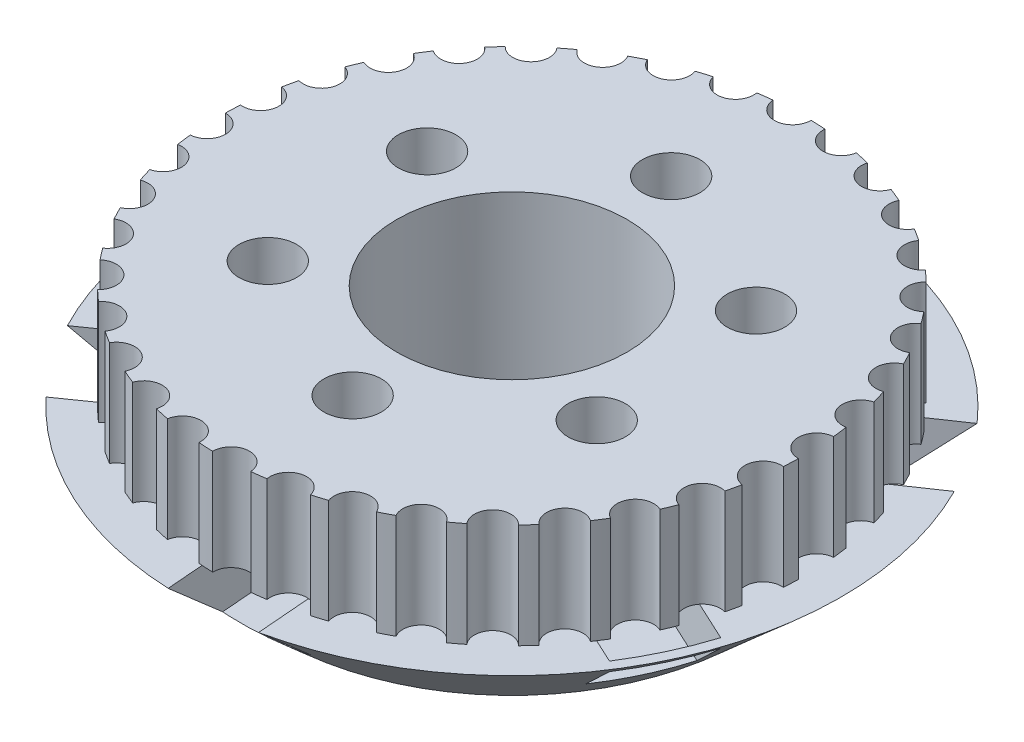
from build123d import *
from build123d.topology import SkipClean

# Parameters (mm, degrees)
SKETCH1_R               = 2.75
SKETCH1_R_2             = 11
BOSS_EXTRUDE1_DEPTH     = 10
SKETCH2_R               = 31.5
SKETCH3_R               = 22.5
CUT_EXTRUDE1_DEPTH      = 49.046852265
CUT_EXTRUDE1_DEPTH_BACK = 49.046852265
SKETCH3_4_R             = 11
CUT_EXTRUDE2_DEPTH      = 46.656325001
CUT_EXTRUDE2_DEPTH_BACK = 46.656325001
SKETCH1_4_R             = 2.75
CUT_EXTRUDE5_DEPTH      = 5


with BuildPart() as part:
    # Sketch1 → Boss-Extrude1 (new body)
    with BuildSketch(Plane(origin=(0, 0, 0), x_dir=(1, 0, 0), z_dir=(0, 1, 0))):
        with BuildLine():
            ThreePointArc((27.993478679, -0.604277614), (26.22801827, 1.074037998), (27.850343554, 2.891083518))
            ThreePointArc((27.850343554, 2.891083518), (27.77024444, 3.579598264), (27.673126544, 4.26591928))
            ThreePointArc((27.673126544, 4.26591928), (25.643050997, 5.612168524), (26.925202872, 7.683322869))
            ThreePointArc((26.925202872, 7.683322869), (26.726761313, 8.347468463), (26.511940461, 9.006498375))
            ThreePointArc((26.511940461, 9.006498375), (24.278932596, 9.979776149), (25.181953525, 12.242108342))
            ThreePointArc((25.181953525, 12.242108342), (24.871199067, 12.861705057), (24.545202484, 13.473419575))
            ThreePointArc((24.545202484, 13.473419575), (22.177111114, 14.044153326), (22.673563263, 16.428923548))
            ThreePointArc((22.673563263, 16.428923548), (22.259938023, 16.985145252), (21.832670949, 17.530957739))
            ThreePointArc((21.832670949, 17.530957739), (19.401449332, 17.681806011), (19.476248255, 20.116554226))
            ThreePointArc((19.476248255, 20.116554226), (18.972320026, 20.592500403), (18.456764755, 21.055826623))
            ThreePointArc((18.456764755, 21.055826623), (16.036284331, 20.782205967), (15.687157298, 23.192953583))
            ThreePointArc((15.687157298, 23.192953583), (15.108237686, 23.574162849), (14.520059104, 23.940924869))
            ThreePointArc((14.520059104, 23.940924869), (12.183864944, 23.251149112), (11.421420006, 25.564646781))
            ThreePointArc((11.421420006, 25.564646781), (10.785099188, 25.839536286), (10.142168805, 26.098590229))
            ThreePointArc((10.142168805, 26.098590229), (7.961244987, 25.013617856), (6.808648646, 27.159571124))
            ThreePointArc((6.808648646, 27.159571124), (6.13426091, 27.319788489), (5.456113839, 27.463263131))
            ThreePointArc((5.456113839, 27.463263131), (3.496726629, 26.01606048), (1.988999942, 27.929265641))
            ThreePointArc((1.988999942, 27.929265641), (1.297036218, 27.969942743), (0.604277614, 27.993478679))
            ThreePointArc((0.604277614, 27.993478679), (0.604339005, 27.985015849), (0.604359469, 27.976552821))
            ThreePointArc((0.604359469, 27.976552821), (-1.082494776, 26.227692446), (-2.891083518, 27.850343554))
            ThreePointArc((-2.891083518, 27.850343554), (-3.579598264, 27.77024444), (-4.26591928, 27.673126544))
            ThreePointArc((-4.26591928, 27.673126544), (-4.243730358, 27.51353932), (-4.236313092, 27.352587731))
            ThreePointArc((-4.236313092, 27.352587731), (-5.770984401, 25.615885812), (-7.683322869, 26.925202872))
            ThreePointArc((-7.683322869, 26.925202872), (-8.347468463, 26.726761313), (-9.006498375, 26.511940461))
            ThreePointArc((-9.006498375, 26.511940461), (-8.923170733, 26.209743316), (-8.895094559, 25.897528103))
            ThreePointArc((-8.895094559, 25.897528103), (-10.279221713, 24.186201991), (-12.242108342, 25.181953525))
            ThreePointArc((-12.242108342, 25.181953525), (-12.861705057, 24.871199067), (-13.473419575, 24.545202484))
            ThreePointArc((-13.473419575, 24.545202484), (-13.292270178, 24.116687878), (-13.230430214, 23.655585188))
            ThreePointArc((-13.230430214, 23.655585188), (-14.466797726, 21.982659109), (-16.428923548, 22.673563263))
            ThreePointArc((-16.428923548, 22.673563263), (-16.985145252, 22.259938023), (-17.530957739, 21.832670949))
            ThreePointArc((-17.530957739, 21.832670949), (-17.219044747, 21.301360185), (-17.110593078, 20.694879288))
            ThreePointArc((-17.110593078, 20.694879288), (-18.203110002, 19.073085218), (-20.116554226, 19.476248255))
            ThreePointArc((-20.116554226, 19.476248255), (-20.592500403, 18.972320026), (-21.055826623, 18.456764755))
            ThreePointArc((-21.055826623, 18.456764755), (-20.585242914, 17.85261337), (-20.417686365, 17.105369953))
            ThreePointArc((-20.417686365, 17.105369953), (-21.371356544, 15.547050725), (-23.192953583, 15.687157299))
            ThreePointArc((-23.192953583, 15.687157299), (-23.574162849, 15.108237686), (-23.940924869, 14.520059104))
            ThreePointArc((-23.940924869, 14.520059104), (-23.289930499, 13.878441572), (-23.051225719, 12.996122607))
            ThreePointArc((-23.051225719, 12.996122607), (-23.872109704, 11.513137972), (-25.564646781, 11.421420006))
            ThreePointArc((-25.564646781, 11.421420006), (-25.839536286, 10.785099188), (-26.098590229, 10.142168805))
            ThreePointArc((-26.098590229, 10.142168805), (-25.252547259, 9.502674185), (-24.93119238, 8.491994653))
            ThreePointArc((-24.93119238, 8.491994653), (-25.626361304, 7.095631018), (-27.159571124, 6.808648646))
            ThreePointArc((-27.159571124, 6.808648646), (-27.319788489, 6.13426091), (-27.463263131, 5.456113839))
            ThreePointArc((-27.463263131, 5.456113839), (-26.415342342, 4.861189956), (-26.000464512, 3.729841738))
            ThreePointArc((-26.000464512, 3.729841738), (-26.577946276, 2.430726274), (-27.929265641, 1.988999942))
            ThreePointArc((-27.929265641, 1.988999942), (-27.969942743, 1.297036218), (-27.993478679, 0.604277614))
            ThreePointArc((-27.993478679, 0.604277614), (-26.745114689, 0.09776613), (-26.226552821, -1.145640531))
            ThreePointArc((-26.226552821, -1.145640531), (-26.695270999, -2.337620771), (-27.850343554, -2.891083518))
            ThreePointArc((-27.850343554, -2.891083518), (-27.77024444, -3.579598264), (-27.673126544, -4.26591928))
            ThreePointArc((-27.673126544, -4.26591928), (-26.234205623, -4.640311063), (-25.602587731, -5.986313092))
            ThreePointArc((-25.602587731, -5.986313092), (-25.972293649, -7.062086418), (-26.925202872, -7.683322869))
            ThreePointArc((-26.925202872, -7.683322869), (-26.726761313, -8.347468463), (-26.511940461, -9.006498375))
            ThreePointArc((-26.511940461, -9.006498375), (-24.900713583, -9.206741051), (-24.147528103, -10.645094559))
            ThreePointArc((-24.147528103, -10.645094559), (-24.428726634, -11.596473687), (-25.181953525, -12.242108342))
            ThreePointArc((-25.181953525, -12.242108342), (-24.871199067, -12.861705057), (-24.545202484, -13.473419575))
            ThreePointArc((-24.545202484, -13.473419575), (-22.787924617, -13.460671966), (-21.905585188, -14.980430214))
            ThreePointArc((-21.905585188, -14.980430214), (-22.109454798, -15.800174574), (-22.673563263, -16.428923548))
            ThreePointArc((-22.673563263, -16.428923548), (-22.259938023, -16.985145252), (-21.832670949, -17.530957739))
            ThreePointArc((-21.832670949, -17.530957739), (-19.962976086, -17.270996367), (-18.944879288, -18.860593078))
            ThreePointArc((-18.944879288, -18.860593078), (-19.083186962, -19.542463921), (-19.476248255, -20.116554226))
            ThreePointArc((-19.476248255, -20.116554226), (-18.972320026, -20.592500403), (-18.456764755, -21.055826623))
            ThreePointArc((-18.456764755, -21.055826623), (-16.514794346, -20.520348982), (-15.355369953, -22.167686365))
            ThreePointArc((-15.355369953, -22.167686365), (-15.440381643, -22.706494241), (-15.687157298, -23.192953583))
            ThreePointArc((-15.687157298, -23.192953583), (-15.108237686, -23.574162849), (-14.520059104, -23.940924869))
            ThreePointArc((-14.520059104, -23.940924869), (-12.551369232, -23.108684897), (-11.246122607, -24.801225719))
            ThreePointArc((-11.246122607, -24.801225719), (-11.29050988, -25.192869976), (-11.421420006, -25.564646781))
            ThreePointArc((-11.421420006, -25.564646781), (-10.785099188, -25.839536286), (-10.142168805, -26.098590229))
            ThreePointArc((-10.142168805, -26.098590229), (-8.196448351, -24.956329376), (-6.741994653, -26.68119238))
            ThreePointArc((-6.741994653, -26.68119238), (-6.75873825, -26.922692368), (-6.808648646, -27.159571124))
            ThreePointArc((-6.808648646, -27.159571124), (-6.13426091, -27.319788489), (-5.456113839, -27.463263131))
            ThreePointArc((-5.456113839, -27.463263131), (-3.585751795, -26.006406574), (-1.979841738, -27.750464512))
            ThreePointArc((-1.979841738, -27.750464512), (-1.982132788, -27.83998227), (-1.988999942, -27.929265641))
            ThreePointArc((-1.988999942, -27.929265641), (-1.297036218, -27.969942743), (-0.604277614, -27.993478679))
            ThreePointArc((-0.604277614, -27.993478679), (1.074037998, -26.22801827), (2.891083518, -27.850343554))
            ThreePointArc((2.891083518, -27.850343554), (3.579598264, -27.77024444), (4.26591928, -27.673126544))
            ThreePointArc((4.26591928, -27.673126544), (5.612168524, -25.643050997), (7.683322869, -26.925202872))
            ThreePointArc((7.683322869, -26.925202872), (8.347468463, -26.726761312), (9.006498375, -26.511940461))
            ThreePointArc((9.006498375, -26.511940461), (9.979776149, -24.278932596), (12.242108342, -25.181953525))
            ThreePointArc((12.242108342, -25.181953525), (12.861705057, -24.871199067), (13.473419575, -24.545202484))
            ThreePointArc((13.473419575, -24.545202484), (14.044153326, -22.177111114), (16.428923548, -22.673563263))
            ThreePointArc((16.428923548, -22.673563263), (16.985145252, -22.259938023), (17.530957739, -21.832670949))
            ThreePointArc((17.530957739, -21.832670949), (17.681806011, -19.401449332), (20.116554226, -19.476248255))
            ThreePointArc((20.116554226, -19.476248255), (20.592500403, -18.972320026), (21.055826623, -18.456764755))
            ThreePointArc((21.055826623, -18.456764755), (20.782205967, -16.036284331), (23.192953583, -15.687157298))
            ThreePointArc((23.192953583, -15.687157298), (23.574162849, -15.108237686), (23.940924869, -14.520059104))
            ThreePointArc((23.940924869, -14.520059104), (23.251149112, -12.183864944), (25.564646781, -11.421420006))
            ThreePointArc((25.564646781, -11.421420006), (25.839536286, -10.785099188), (26.098590229, -10.142168805))
            ThreePointArc((26.098590229, -10.142168805), (25.013617856, -7.961244987), (27.159571124, -6.808648646))
            ThreePointArc((27.159571124, -6.808648646), (27.319788489, -6.13426091), (27.463263131, -5.456113839))
            ThreePointArc((27.463263131, -5.456113839), (26.01606048, -3.496726629), (27.929265641, -1.988999942))
            ThreePointArc((27.929265641, -1.988999942), (27.969942743, -1.297036218), (27.993478679, -0.604277614))
        make_face()
        with Locations((-13.718248072, -9.611044159)):
            Circle(SKETCH1_R, mode=Mode.SUBTRACT)
        Circle(SKETCH1_R_2, mode=Mode.SUBTRACT)
        with Locations((1.464284363, -16.685873406)):
            Circle(SKETCH1_R, mode=Mode.SUBTRACT)
        with Locations((15.182532435, -7.074829246)):
            Circle(SKETCH1_R, mode=Mode.SUBTRACT)
        with Locations((-15.182532435, 7.074829246)):
            Circle(SKETCH1_R, mode=Mode.SUBTRACT)
        with Locations((-1.464284363, 16.685873406)):
            Circle(SKETCH1_R, mode=Mode.SUBTRACT)
        with Locations((13.718248072, 9.611044159)):
            Circle(SKETCH1_R, mode=Mode.SUBTRACT)
    extrude(amount=BOSS_EXTRUDE1_DEPTH)

    # Sketch2 → Loft2 section 0
    with BuildSketch(Plane.XZ):
        Circle(SKETCH2_R)
    # Sketch3 → Loft2 section 1
    with BuildSketch(Plane(origin=(0, -8, 0), x_dir=(-1, 0, 0), z_dir=(0, -1, 0))):
        Circle(SKETCH3_R)
    loft()

    # Sketch3_4 → Cut-Extrude1 (cut, two sides: drawn at the far end of the back side and taken through both)
    with SkipClean():  # the faces are left unmerged after this step: merging them gives an invalid solid
        with BuildSketch(Plane(origin=(0, -8, 0), x_dir=(-1, 0, 0), z_dir=(0, -1, 0)).offset(-CUT_EXTRUDE1_DEPTH_BACK)):
            Circle(SKETCH3_4_R)
        extrude(amount=CUT_EXTRUDE1_DEPTH + CUT_EXTRUDE1_DEPTH_BACK, mode=Mode.SUBTRACT)
    add(part.part.scale(1), mode=Mode.REPLACE)  # the faces are merged on a copy

    # Sketch1_4 → Cut-Extrude2 (cut, two sides: drawn at the far end of the back side and taken through both)
    with BuildSketch(Plane(origin=(0, 0, 0), x_dir=(1, 0, 0), z_dir=(0, 1, 0)).offset(-CUT_EXTRUDE2_DEPTH_BACK)):
        with Locations((-1.464284363, 16.685873406)):
            Circle(SKETCH1_4_R)
        with Locations((13.718248072, 9.611044159)):
            Circle(SKETCH1_4_R)
        with Locations((15.182532435, -7.074829246)):
            Circle(SKETCH1_4_R)
        with Locations((1.464284363, -16.685873406)):
            Circle(SKETCH1_4_R)
        with Locations((-13.718248072, -9.611044159)):
            Circle(SKETCH1_4_R)
        with Locations((-15.182532435, 7.074829246)):
            Circle(SKETCH1_4_R)
    extrude(amount=CUT_EXTRUDE2_DEPTH + CUT_EXTRUDE2_DEPTH_BACK, mode=Mode.SUBTRACT)

    # Sketch5 → Cut-Extrude5 (cut)
    with BuildSketch(Plane(origin=(0, 0, 0), x_dir=(1, 0, 0), z_dir=(0, 1, 0))):
        with BuildLine():
            Line((-1.010859951, 11.518992898), (2.749879224, 14.420602944))
            Line((2.749879224, 14.420602944), (1.383982586, 31.469582015))
            ThreePointArc((1.383982586, 31.469582015), (-2.688549449, 31.38505539), (-6.716122863, 30.775699727))
            Line((-6.716122863, 30.775699727), (-5.219493149, 13.721243248))
            Line((-5.219493149, 13.721243248), (-1.010859951, 11.518992898))
        make_face()
        with BuildLine():
            Line((-10.481170451, 4.884066051), (-11.89697097, 10.234856986))
            Line((-11.89697097, 10.234856986), (-26.561466178, 16.933355085))
            ThreePointArc((-26.561466178, 16.933355085), (-28.552225176, 13.304902761), (-30.050099314, 9.446773588))
            Line((-30.050099314, 9.446773588), (-14.492691799, 2.340407962))
            Line((-14.492691799, 2.340407962), (-10.481170451, 4.884066051))
        make_face()
        with BuildLine():
            Line((9.088959443, 6.062273545), (13.329497552, 4.026882724))
            Line((13.329497552, 4.026882724), (28.157752403, 14.120587084))
            ThreePointArc((28.157752403, 14.120587084), (26.107710832, 17.624909507), (23.623976149, 20.836452455))
            Line((23.623976149, 20.836452455), (8.891847592, 10.808181985))
            Line((8.891847592, 10.808181985), (9.088959443, 6.062273545))
        make_face()
        with BuildLine():
            Line((10.481170451, -4.884066051), (11.113668875, -9.591766737))
            Line((11.113668875, -9.591766737), (25.72692502, -16.401321888))
            ThreePointArc((25.72692502, -16.401321888), (27.655135877, -12.886872789), (29.105947943, -9.149963113))
            Line((29.105947943, -9.149963113), (14.492691799, -2.340407962))
            Line((14.492691799, -2.340407962), (10.481170451, -4.884066051))
        make_face()
        with BuildLine():
            Line((1.010859951, -11.518992898), (-2.749879224, -14.420602944))
            Line((-2.749879224, -14.420602944), (-1.383982586, -31.469582015))
            ThreePointArc((-1.383982586, -31.469582015), (2.623266489, -31.390579366), (6.588045516, -30.803370859))
            Line((6.588045516, -30.803370859), (5.219493149, -13.721243248))
            Line((5.219493149, -13.721243248), (1.010859951, -11.518992898))
        make_face()
        with BuildLine():
            Line((-10.348335344, -7.091644092), (-14.741572943, -5.285553452))
            Line((-14.741572943, -5.285553452), (-27.945448765, -14.53622693))
            ThreePointArc((-27.945448765, -14.53622693), (-25.734461307, -18.165558104), (-23.055066187, -21.464247556))
            Line((-23.055066187, -21.464247556), (-9.807249197, -12.182788769))
            Line((-9.807249197, -12.182788769), (-10.348335344, -7.091644092))
        make_face()
    extrude(amount=-CUT_EXTRUDE5_DEPTH, mode=Mode.SUBTRACT)


solid = part.part
